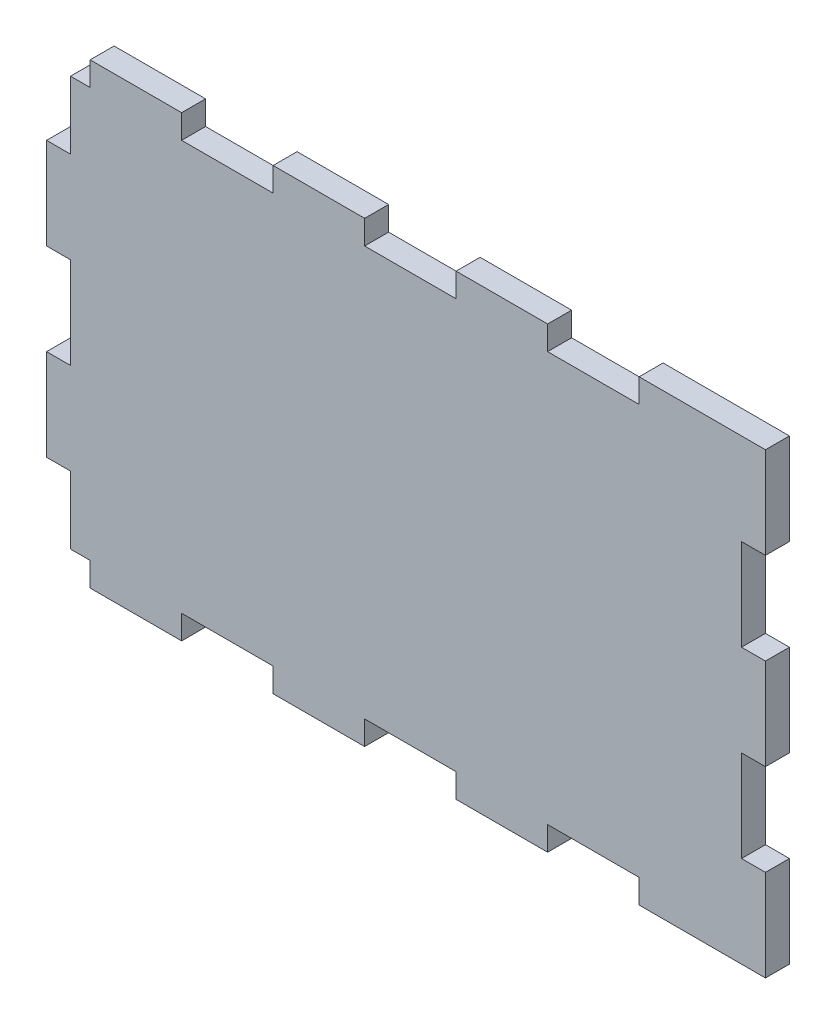
from build123d import *

# Parameters (mm, degrees)
SALIENTE_EXTRUIR1_DEPTH = 5.5
CROQUIS2_W              = 26.5
CROQUIS2_H              = 5.5
CROQUIS2_W_2            = 21
SALIENTE_EXTRUIR2_DEPTH = 2.5
CROQUIS3_W              = 5.5
CROQUIS3_H              = 18.5
CROQUIS3_H_2            = 21
SALIENTE_EXTRUIR3_DEPTH = 2.5
CROQUIS4_W              = 21
CROQUIS4_H              = 5.5
CROQUIS4_W_2            = 29
SALIENTE_EXTRUIR4_DEPTH = 2.5
CROQUIS5_W              = 5.5
CROQUIS5_H              = 21
SALIENTE_EXTRUIR5_DEPTH = 2.5


with BuildPart() as part:
    # Croquis1 → Saliente-Extruir1 (new body)
    with BuildSketch(Plane.XY):
        Polygon((-57, -53.354967587), (-52.5, -53.354967587), (-52.5, -56.354967587), (-31.5, -56.354967587), (-31.5, -53.354967587), (-10.5, -53.354967587), (-10.5, -56.354967587), (10.5, -56.354967587), (10.5, -53.354967587), (31.5, -53.354967587), (31.5, -56.354967587), (52.5, -56.354967587), (52.5, -53.354967587), (73.5, -53.354967587), (73.5, -56.354967587), (94.5, -56.354967587), (100, -56.354967587), (100, -37.854967587), (97, -37.854967587), (97, -16.854967587), (100, -16.854967587), (100, 4.145032413), (97, 4.145032413), (97, 25.145032413), (100, 25.145032413), (100, 43.645032413), (73.5, 43.645032413), (73.5, 40.645032413), (52.5, 40.645032413), (52.5, 43.645032413), (31.5, 43.645032413), (31.5, 40.645032413), (10.5, 40.645032413), (10.5, 43.645032413), (-10.5, 43.645032413), (-10.5, 40.645032413), (-31.5, 40.645032413), (-31.5, 43.645032413), (-52.5, 43.645032413), (-52.5, 40.645032413), (-57, 40.645032413), (-57, 25.145032413), (-60, 25.145032413), (-60, 4.145032413), (-57, 4.145032413), (-57, -16.854967587), (-60, -16.854967587), (-60, -37.854967587), (-57, -37.854967587), align=None)
    extrude(amount=SALIENTE_EXTRUIR1_DEPTH)

    # Croquis2 → Saliente-Extruir2 (add)
    with BuildSketch(Plane(origin=(0, 43.645032413, 0), x_dir=(1, 0, 0), z_dir=(0, 1, 0))):
        with Locations((86.75, -2.75)):
            Rectangle(CROQUIS2_W, CROQUIS2_H)
        with Locations((42, -2.75)):
            Rectangle(CROQUIS2_W_2, CROQUIS2_H)
        with Locations((0, -2.75)):
            Rectangle(CROQUIS2_W_2, CROQUIS2_H)
        with Locations((-42, -2.75)):
            Rectangle(CROQUIS2_W_2, CROQUIS2_H)
    extrude(amount=SALIENTE_EXTRUIR2_DEPTH)

    # Croquis3 → Saliente-Extruir3 (add)
    with BuildSketch(Plane(origin=(100, 0, 0), x_dir=(0, 0, -1), z_dir=(1, 0, 0))):
        with Locations((-2.75, -47.104967587)):
            Rectangle(CROQUIS3_W, CROQUIS3_H)
        with Locations((-2.75, -6.354967587)):
            Rectangle(CROQUIS3_W, CROQUIS3_H_2)
        with Locations((-2.75, 35.645032413)):
            Rectangle(CROQUIS3_W, CROQUIS3_H_2)
    extrude(amount=SALIENTE_EXTRUIR3_DEPTH)

    # Croquis4 → Saliente-Extruir4 (add)
    with BuildSketch(Plane.XZ.offset(56.354967587)):
        with Locations((-42, 2.75)):
            Rectangle(CROQUIS4_W, CROQUIS4_H)
        with Locations((0, 2.75)):
            Rectangle(CROQUIS4_W, CROQUIS4_H)
        with Locations((42, 2.75)):
            Rectangle(CROQUIS4_W, CROQUIS4_H)
        with Locations((88, 2.75)):
            Rectangle(CROQUIS4_W_2, CROQUIS4_H)
    extrude(amount=SALIENTE_EXTRUIR4_DEPTH)

    # Croquis5 → Saliente-Extruir5 (add)
    with BuildSketch(Plane.ZY.offset(60)):
        with Locations((2.75, -27.354967587)):
            Rectangle(CROQUIS5_W, CROQUIS5_H)
        with Locations((2.75, 14.645032413)):
            Rectangle(CROQUIS5_W, CROQUIS5_H)
    extrude(amount=SALIENTE_EXTRUIR5_DEPTH)


solid = part.part
